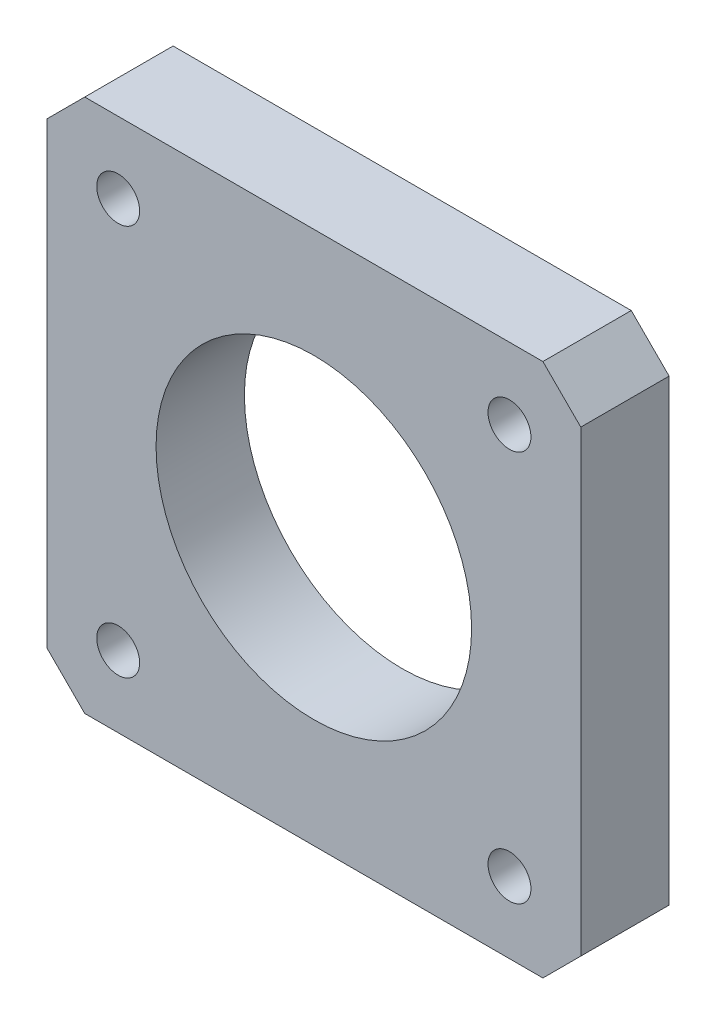
from build123d import *

# Parameters (mm, degrees)
SKETCH1_W                = 42.3
SKETCH1_H                = 42.3
SKETCH1_R                = 12.5
BOSS_EXTRUDE1_DEPTH      = 7
CHAMFER1_SIZE            = 3
M3_CLEARANCE_HOLE1_D     = 3.4
M3_CLEARANCE_HOLE1_DEPTH = 7.5
M3_CLEARANCE_HOLE1_TIP   = 1.021463052


with BuildPart() as part:
    # Sketch1 → Boss-Extrude1 (new body)
    with BuildSketch(Plane.XY):
        Rectangle(SKETCH1_W, SKETCH1_H)
        Circle(SKETCH1_R, mode=Mode.SUBTRACT)
    extrude(amount=BOSS_EXTRUDE1_DEPTH)

    # Chamfer1
    chamfer1_edges = [part.edges().sort_by_distance(p)[0] for p in [
        (21.15, -21.15, 3.5),
        (-21.15, -21.15, 3.5),
        (-21.15, 21.15, 3.5),
        (21.15, 21.15, 3.5),
    ]]
    chamfer(chamfer1_edges, length=CHAMFER1_SIZE)

    # M3 Clearance Hole1
    with Locations(Plane.XY.offset(7)):
        with Locations((15.5, 15.5), (-15.5, 15.5), (-15.5, -15.5), (15.5, -15.5)):
            Hole(M3_CLEARANCE_HOLE1_D / 2, depth=M3_CLEARANCE_HOLE1_DEPTH)
            with Locations((0, 0, -(M3_CLEARANCE_HOLE1_DEPTH + M3_CLEARANCE_HOLE1_TIP / 2))):  # 118° drill point
                Cone(0, M3_CLEARANCE_HOLE1_D / 2, M3_CLEARANCE_HOLE1_TIP, mode=Mode.SUBTRACT)


solid = part.part
